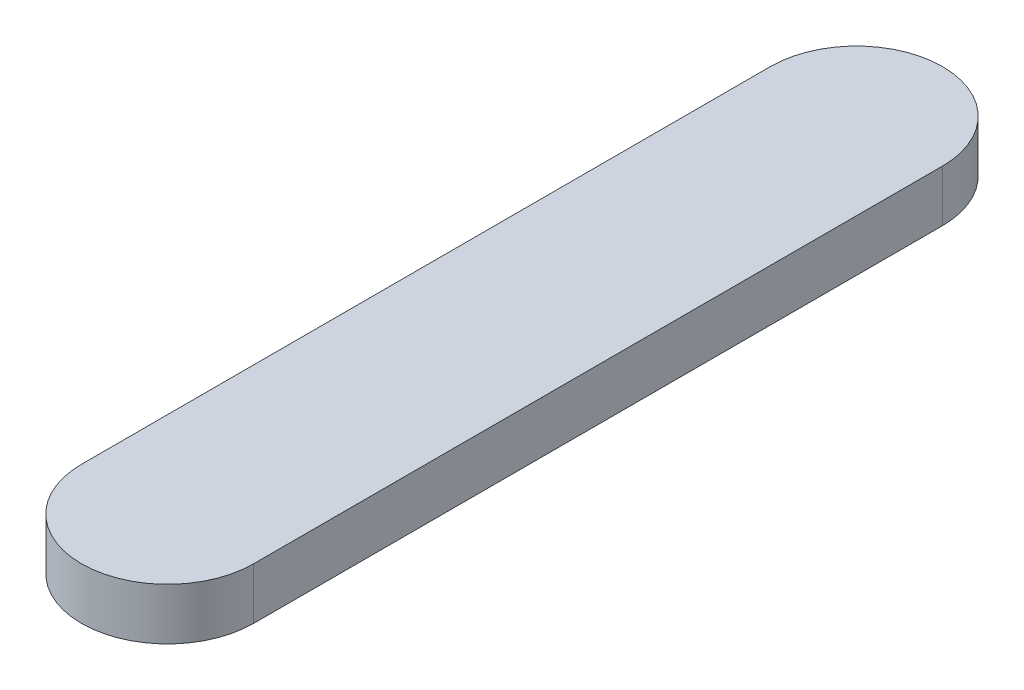
from build123d import *

# Parameters (mm, degrees)
EXTRUDE_1_DEPTH = 30


with BuildPart() as part:
    # 草图1 → 凸台-拉伸1 (new body)
    with BuildSketch(Plane(origin=(0, 0, 0), x_dir=(1, 0, 0), z_dir=(0, 1, 0))):
        with BuildLine():
            Line((50, 200), (50, -200))
            ThreePointArc((50, -200), (0, -250), (-50, -200))
            Line((-50, -200), (-50, 200))
            ThreePointArc((-50, 200), (0, 250), (50, 200))
        make_face()
    extrude(amount=EXTRUDE_1_DEPTH)


solid = part.part
